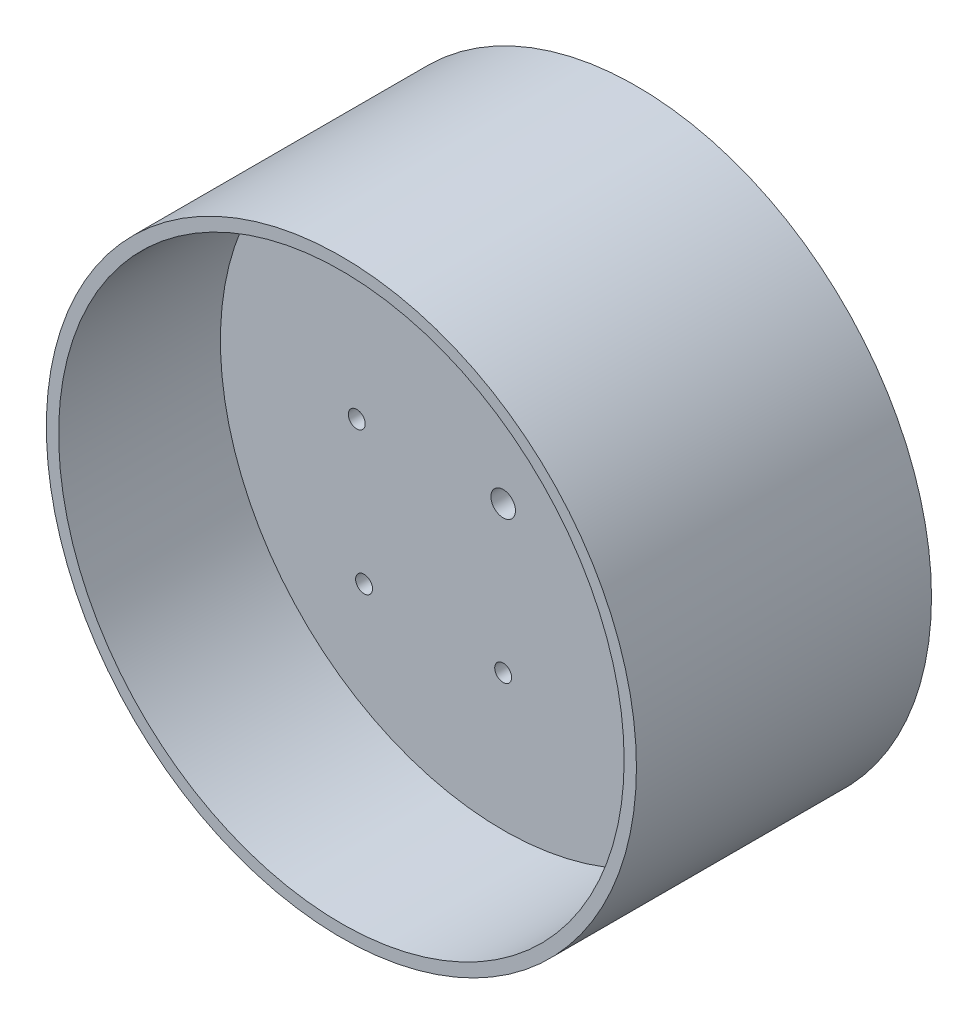
from build123d import *

# Parameters (mm, degrees)
SKETCH1_R           = 76.2
SKETCH1_R_2         = 73.025
BOSS_EXTRUDE1_DEPTH = 76.2
SKETCH3_R           = 76.2
BOSS_EXTRUDE2_DEPTH = 34.417
SKETCH5_R           = 2.1828125
CUT_EXTRUDE2_DEPTH  = 35.417
SKETCH11_R          = 2.1828125
CUT_EXTRUDE11_DEPTH = 35.417
SKETCH12_R          = 3.175
CUT_EXTRUDE12_DEPTH = 35.417


with BuildPart() as part:
    # Sketch1 → Boss-Extrude1 (new body)
    with BuildSketch(Plane.XY):
        Circle(SKETCH1_R)
        Circle(SKETCH1_R_2, mode=Mode.SUBTRACT)
    extrude(amount=BOSS_EXTRUDE1_DEPTH)

    # Sketch3 → Boss-Extrude2 (add)
    with BuildSketch(Plane.XY):
        Circle(SKETCH3_R)
    extrude(amount=BOSS_EXTRUDE2_DEPTH)

    # Sketch5 → Cut-Extrude2 (cut, through all)
    with BuildSketch(Plane.XY.offset(34.417)):
        with Locations((0, 37.81298)):
            Circle(SKETCH5_R)
        with Locations((37.81298, 0)):
            Circle(SKETCH5_R)
        with Locations((-37.81298, 0)):
            Circle(SKETCH5_R)
        with Locations((0, -37.81298)):
            Circle(SKETCH5_R)
    extrude(amount=-CUT_EXTRUDE2_DEPTH, mode=Mode.SUBTRACT)

    # Sketch11 → Cut-Extrude11 (cut, through all)
    with BuildSketch(Plane.XY.offset(34.417)):
        with Locations((-35.921024484, 35.921024484)):
            Circle(SKETCH11_R)
        with Locations((-35.921024484, -35.921024484)):
            Circle(SKETCH11_R)
        with Locations((35.921024484, -35.921024484)):
            Circle(SKETCH11_R)
        with Locations((35.921024484, 35.921024484)):
            Circle(SKETCH11_R)
    extrude(amount=-CUT_EXTRUDE11_DEPTH, mode=Mode.SUBTRACT)

    # Sketch12 → Cut-Extrude12 (cut, through all)
    with BuildSketch(Plane.XY.offset(34.417)):
        Circle(SKETCH12_R)
    extrude(amount=-CUT_EXTRUDE12_DEPTH, mode=Mode.SUBTRACT)


solid = part.part
